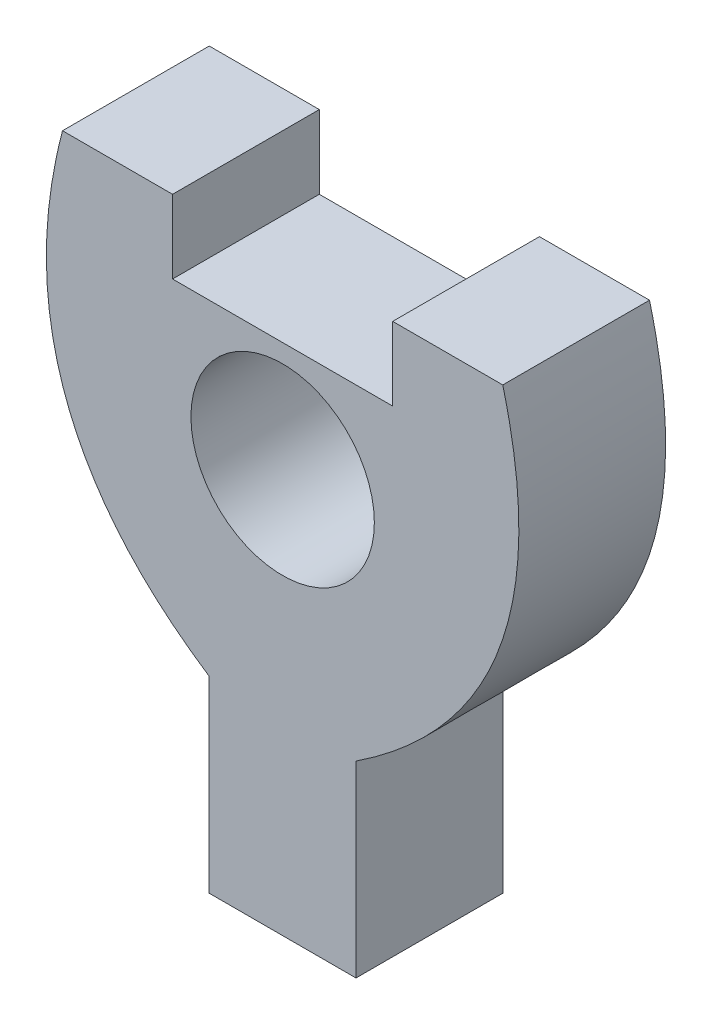
from build123d import *

# Parameters (mm, degrees)
SKETCH1_R           = 2.5
BOSS_EXTRUDE1_DEPTH = 4


with BuildPart() as part:
    # Sketch1 → Boss-Extrude1 (new body)
    with BuildSketch(Plane.XY):
        with BuildLine():
            Line((2, -4), (2, 1.120548597))
            add(Edge.make_bspline(
                [(2, 1.120548597), (7.835899457, 4.971392719), (6, 12)],
                knots=[0.134548696, 0.134548696, 0.134548696, 1, 1, 1], degree=2))
            Line((6, 12), (3, 12))
            Line((3, 12), (3, 10))
            Line((3, 10), (-3, 10))
            Line((-3, 10), (-3, 12))
            Line((-3, 12), (-6, 12))
            add(Edge.make_bspline(
                [(-2, 1.120548597), (-7.835899457, 4.971392719), (-6, 12)],
                knots=[0.134548696, 0.134548696, 0.134548696, 1, 1, 1], degree=2))
            Line((-2, 1.120548597), (-2, -4))
            Line((-2, -4), (2, -4))
        make_face()
        with Locations((0, 7)):
            Circle(SKETCH1_R, mode=Mode.SUBTRACT)
    extrude(amount=BOSS_EXTRUDE1_DEPTH)


solid = part.part
